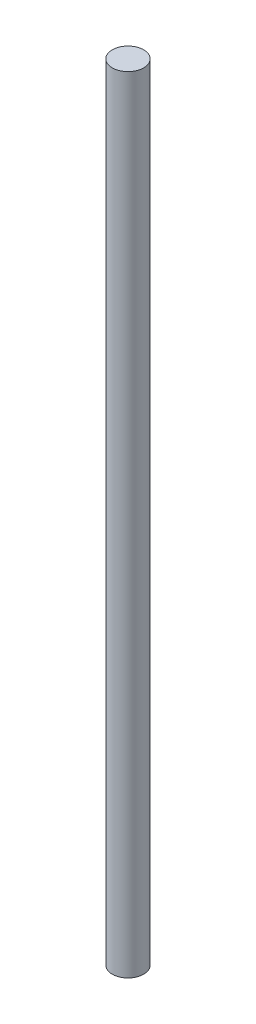
from build123d import *

# Parameters (mm, degrees)
SKETCH1_R                 = 4
BOSS_EXTRUDE1_DEPTH       = 200
M4X0_7_TAPPED_HOLE1_D     = 3.3
M4X0_7_TAPPED_HOLE1_DEPTH = 9.1
M4X0_7_TAPPED_HOLE1_TIP   = 0.991420021


with BuildPart() as part:
    # Sketch1 → Boss-Extrude1 (new body)
    with BuildSketch(Plane(origin=(0, 0, 0), x_dir=(1, 0, 0), z_dir=(0, 1, 0))):
        Circle(SKETCH1_R)
    extrude(amount=BOSS_EXTRUDE1_DEPTH)

    # M4x0.7 Tapped Hole1
    with Locations(Plane(origin=(0, 0, 0), x_dir=(-1, 0, 0), z_dir=(0, -1, 0))):
        with Locations((0, 0)):
            Hole(M4X0_7_TAPPED_HOLE1_D / 2, depth=M4X0_7_TAPPED_HOLE1_DEPTH)
            with Locations((0, 0, -(M4X0_7_TAPPED_HOLE1_DEPTH + M4X0_7_TAPPED_HOLE1_TIP / 2))):  # 118° drill point
                Cone(0, M4X0_7_TAPPED_HOLE1_D / 2, M4X0_7_TAPPED_HOLE1_TIP, mode=Mode.SUBTRACT)


solid = part.part
